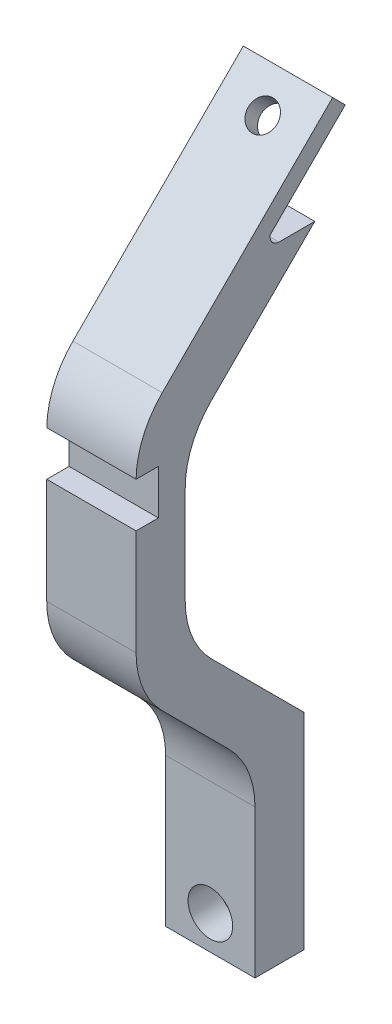
from build123d import *

# Parameters (mm, degrees)
ESTRUSIONE_ESTRUSIONE1_DEPTH = 5
SCHIZZO2_R                   = 1.625
TAGLIO_ESTRUSIONE1_DEPTH     = 11.10267083
SCHIZZO3_R                   = 2.5
TAGLIO_ESTRUSIONE2_DEPTH     = 3.5
RACCORDO1_R                  = 10
SCHIZZO4_W                   = 2.5
SCHIZZO4_H                   = 5
TAGLIO_ESTRUSIONE3_DEPTH     = 10
RACCORDO2_R                  = 1
SCHIZZO5_R                   = 1.625
TAGLIO_ESTRUSIONE4_DEPTH     = 10


with BuildPart() as part:
    # Schizzo1 → Estrusione-Estrusione1 (new body, symmetric)
    with BuildSketch(Plane(origin=(0, 0, 0), x_dir=(0, 0, -1), z_dir=(1, 0, 0))):
        Polygon((-21.188457268, 88.94490566), (-26.688457268, 88.94490566), (-26.688457268, 109.666731067), (-40, 122.978273799), (-40, 147.94490566), (-18, 169.94490566), (-16.585786438, 168.530692098), (-25, 160.116478536), (-25, 158.94490566), (-20, 158.94490566), (-34.5, 144.44490566), (-34.5, 125.256448392), (-21.188457268, 111.94490566), align=None)
    extrude(amount=ESTRUSIONE_ESTRUSIONE1_DEPTH, both=True)

    # Schizzo2 → Taglio-Estrusione1 (cut, through all)
    with BuildSketch(Plane.XY.offset(26.688457268)):
        with Locations((0, 92.723474812)):
            Circle(SCHIZZO2_R)
    extrude(amount=-TAGLIO_ESTRUSIONE1_DEPTH, mode=Mode.SUBTRACT)

    # Schizzo3 → Taglio-Estrusione2 (cut)
    with BuildSketch(Plane.XY.offset(26.688457268)):
        with Locations((0, 92.723474812)):
            Circle(SCHIZZO3_R)
    extrude(amount=-TAGLIO_ESTRUSIONE2_DEPTH, mode=Mode.SUBTRACT)

    # Raccordo1
    raccordo1_edges = [part.edges().sort_by_distance(p)[0] for p in [
        (0, 109.666731067, 26.688457268),
        (0, 122.978273799, 40),
        (0, 147.94490566, 40),
        (0, 144.44490566, 34.5),
        (0, 125.256448392, 34.5),
    ]]
    fillet(raccordo1_edges, radius=RACCORDO1_R)

    # Schizzo4 → Taglio-Estrusione3 (cut)
    with BuildSketch(Plane.ZY.offset(5)):
        with Locations((38.75, 141.44490566)):
            Rectangle(SCHIZZO4_W, SCHIZZO4_H)
    extrude(amount=-TAGLIO_ESTRUSIONE3_DEPTH, mode=Mode.SUBTRACT)

    # Raccordo2
    raccordo2_edges = [part.edges().sort_by_distance(p)[0] for p in [
        (0, 158.94490566, 25),
    ]]
    fillet(raccordo2_edges, radius=RACCORDO2_R)

    # Schizzo5 → Taglio-Estrusione4 (cut)
    with BuildSketch(Plane(origin=(0, 93.97245283, 93.97245283), x_dir=(1, 0, 0), z_dir=(0, 0.707106781, 0.707106781))):
        with Locations((0, 103.441273159)):
            Circle(SCHIZZO5_R)
    extrude(amount=-TAGLIO_ESTRUSIONE4_DEPTH, mode=Mode.SUBTRACT)


solid = part.part
